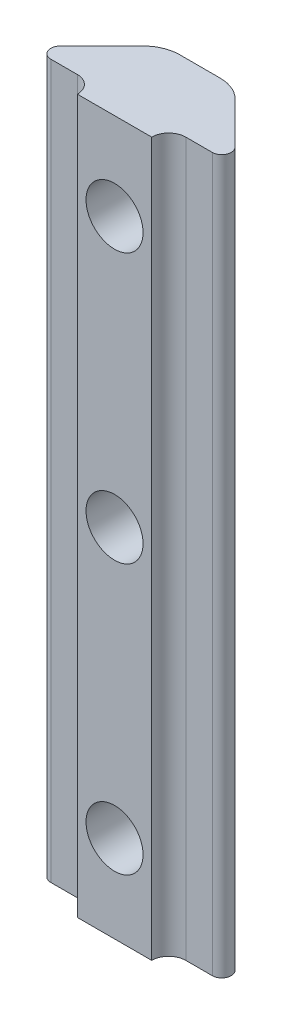
from build123d import *

# Parameters (mm, degrees)
BOSS_EXTRUDE1_DEPTH = 57.15
SKETCH2_R           = 2.286
CUT_EXTRUDE1_DEPTH  = 7.8393


with BuildPart() as part:
    # Sketch1 → Boss-Extrude1 (new body)
    with BuildSketch(Plane(origin=(0, 0, 0), x_dir=(1, 0, 0), z_dir=(0, 1, 0))):
        with BuildLine():
            Line((-2.9785, -6.8393), (2.978499971, -6.8393))
            ThreePointArc((2.978499971, -6.8393), (3.378269925, -5.874169954), (4.343399971, -5.4744))
            Line((4.343399971, -5.4744), (6.474794456, -5.4744))
            ThreePointArc((6.474794456, -5.4744), (7.173247382, -5.007708675), (7.009367182, -4.183827273))
            Line((7.009367182, -4.183827273), (3.679323642, -0.853783733))
            ThreePointArc((3.679323642, -0.853783733), (2.73362958, -0.221891163), (1.618107374, 0))
            Line((1.618107374, 0), (-1.618107374, 0))
            ThreePointArc((-1.618107374, 0), (-2.73362958, -0.221891163), (-3.679323642, -0.853783733))
            Line((-3.679323642, -0.853783733), (-7.009367182, -4.183827273))
            ThreePointArc((-7.009367182, -4.183827273), (-7.173247382, -5.007708675), (-6.474794456, -5.4744))
            Line((-6.474794456, -5.4744), (-4.3434, -5.4744))
            ThreePointArc((-4.3434, -5.4744), (-3.378269954, -5.874169954), (-2.9785, -6.8393))
        make_face()
    extrude(amount=BOSS_EXTRUDE1_DEPTH)

    # Sketch2 → Cut-Extrude1 (cut, through all)
    with BuildSketch(Plane.XY.offset(6.8393)):
        with Locations((0, 50.165)):
            Circle(SKETCH2_R)
        with Locations((0, 28.575)):
            Circle(SKETCH2_R)
        with Locations((0, 6.985)):
            Circle(SKETCH2_R)
    extrude(amount=-CUT_EXTRUDE1_DEPTH, mode=Mode.SUBTRACT)


solid = part.part
